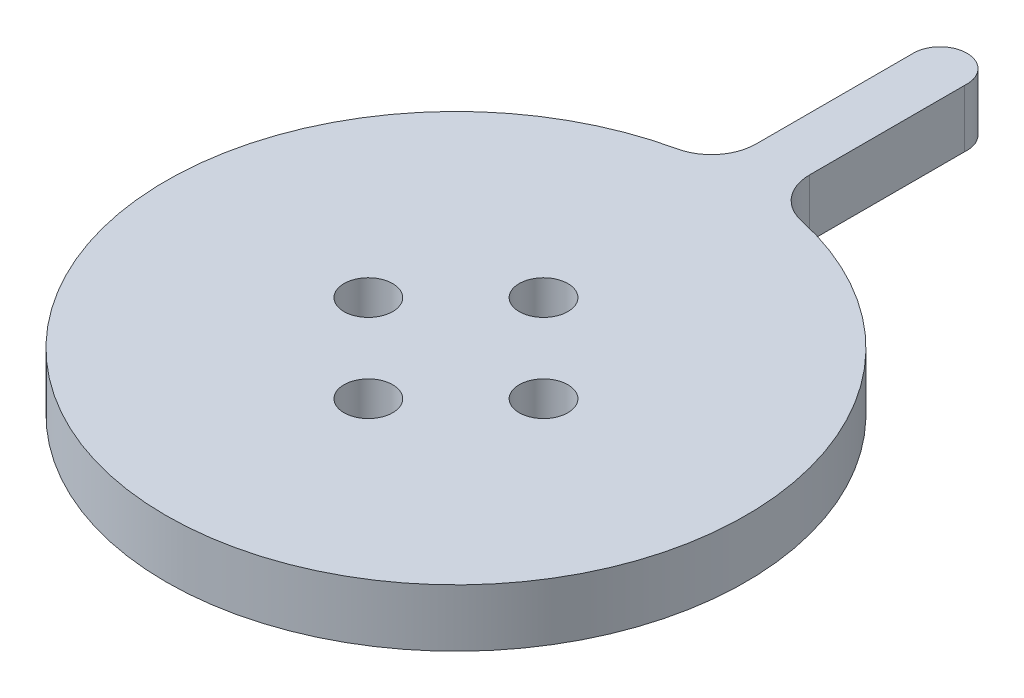
from build123d import *

# Parameters (mm, degrees)
SKETCH2_R           = 32.76798012
BOSS_EXTRUDE1_DEPTH = 5
SKETCH3_R           = 32.76798012
SKETCH3_R_2         = 30.26798012
BOSS_EXTRUDE2_DEPTH = 1.5
SKETCH4_R           = 2.75
CUT_EXTRUDE1_DEPTH  = 9.8994949
BOSS_EXTRUDE3_DEPTH = 6.5


with BuildPart() as part:
    # Sketch2 → Boss-Extrude1 (new body)
    with BuildSketch(Plane(origin=(0, 0, 0), x_dir=(1, 0, 0), z_dir=(0, 1, 0))):
        Circle(SKETCH2_R)
    extrude(amount=BOSS_EXTRUDE1_DEPTH)

    # Sketch3 → Boss-Extrude2 (add)
    with BuildSketch(Plane.XZ):
        Circle(SKETCH3_R)
        Circle(SKETCH3_R_2, mode=Mode.SUBTRACT)
    extrude(amount=BOSS_EXTRUDE2_DEPTH)

    # Sketch4 → Cut-Extrude1 (cut)
    with BuildSketch(Plane(origin=(0, 5, 0), x_dir=(1, 0, 0), z_dir=(0, 1, 0))):
        with Locations((0, 9.8994949)):
            Circle(SKETCH4_R)
        with Locations((-9.9, 0)):
            Circle(SKETCH4_R)
        with Locations((9.9, 0)):
            Circle(SKETCH4_R)
        with Locations((0, -9.9)):
            Circle(SKETCH4_R)
    extrude(amount=-CUT_EXTRUDE1_DEPTH, mode=Mode.SUBTRACT)

    # Sketch5 → Boss-Extrude3 (add)
    with BuildSketch(Plane(origin=(0, 5, 0), x_dir=(1, 0, 0), z_dir=(0, 1, 0))):
        with BuildLine():
            Line((-3.023415672, 36.951680319), (-3.023415672, 54.951680319))
            ThreePointArc((-3.023415672, 54.951680319), (0.237235199, 57.737860793), (3.023415672, 54.477209922))
            Line((3.023415672, 54.477209922), (3.023415672, 36.951680319))
            ThreePointArc((3.023415672, 36.951680319), (4.141073493, 33.780800032), (7, 32.011568552))
            ThreePointArc((7, 32.011568552), (0, 32.76798012), (-7, 32.011568552))
            ThreePointArc((-7, 32.011568552), (-4.141073493, 33.780800032), (-3.023415672, 36.951680319))
        make_face()
    extrude(amount=-BOSS_EXTRUDE3_DEPTH)


solid = part.part
